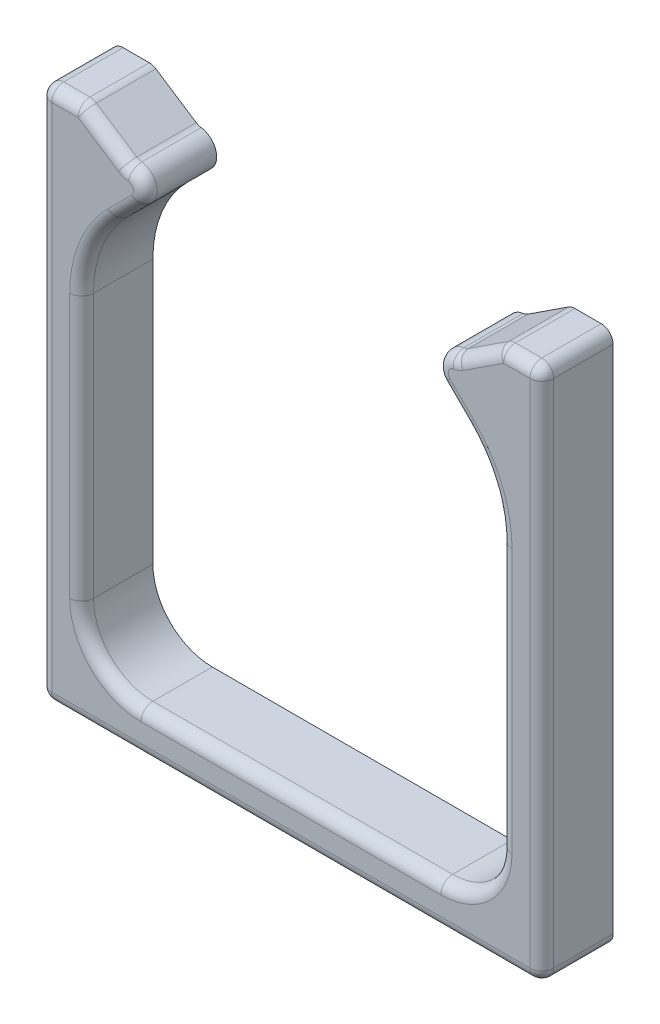
from build123d import *

# Parameters (mm, degrees)
BOSS_EXTRUDE1_DEPTH = 6
FILLET2_R           = 1


with BuildPart() as part:
    # Sketch1 → Boss-Extrude1 (new body)
    with BuildSketch(Plane.XY):
        with BuildLine():
            ThreePointArc((-157.718887647, -39.971100876), (-157.425994428, -40.678207657), (-156.718887647, -40.971100876))
            Line((-156.718887647, -40.971100876), (-154.209280647, -40.971100876))
            Line((-154.209280647, -40.971100876), (-118.966369371, -40.971100876))
            Line((-118.966369371, -40.971100876), (-116.875365395, -40.971100876))
            Line((-116.875365395, -40.971100876), (-116.456762371, -40.971100876))
            ThreePointArc((-116.456762371, -40.971100876), (-115.749655589, -40.678207657), (-115.456762371, -39.971100876))
            Line((-115.456762371, -39.971100876), (-115.456762371, 3.028899124))
            ThreePointArc((-115.456762371, 3.028899124), (-115.749655589, 3.736005905), (-116.456762371, 4.028899124))
            Line((-116.456762371, 4.028899124), (-118.668700725, 4.028899124))
            ThreePointArc((-118.668700725, 4.028899124), (-118.953997988, 3.987338205), (-119.215580818, 3.866110067))
            Line((-119.215580818, 3.866110067), (-122.622400092, 1.640719134))
            ThreePointArc((-122.622400092, 1.640719134), (-122.820936659, 1.540563133), (-123.036698115, 1.486758046))
            ThreePointArc((-123.036698115, 1.486758046), (-124.259059599, 0.479679308), (-123.896981272, -1.062161951))
            Line((-123.896981272, -1.062161951), (-121.905327613, -3.048179664))
            ThreePointArc((-121.905327613, -3.048179664), (-119.730287475, -6.295880771), (-118.966369371, -10.129259334))
            Line((-118.966369371, -10.129259334), (-118.966369371, -32.384364229))
            ThreePointArc((-118.966369371, -32.384364229), (-120.430835465, -35.919898135), (-123.966369371, -37.384364229))
            Line((-123.966369371, -37.384364229), (-149.209280647, -37.384364229))
            ThreePointArc((-149.209280647, -37.384364229), (-152.744814552, -35.919898135), (-154.209280647, -32.384364229))
            Line((-154.209280647, -32.384364229), (-154.209280647, -10.129259334))
            ThreePointArc((-154.209280647, -10.129259334), (-153.445362542, -6.295880771), (-151.270322404, -3.048179664))
            Line((-151.270322404, -3.048179664), (-149.278668745, -1.062161951))
            ThreePointArc((-149.278668745, -1.062161951), (-148.916590418, 0.479679308), (-150.138951903, 1.486758046))
            ThreePointArc((-150.138951903, 1.486758046), (-150.354713358, 1.540563133), (-150.553249925, 1.640719134))
            Line((-150.553249925, 1.640719134), (-153.960069199, 3.866110067))
            ThreePointArc((-153.960069199, 3.866110067), (-154.221652029, 3.987338205), (-154.506949292, 4.028899124))
            Line((-154.506949292, 4.028899124), (-156.718887647, 4.028899124))
            ThreePointArc((-156.718887647, 4.028899124), (-157.425994428, 3.736005905), (-157.718887647, 3.028899124))
            Line((-157.718887647, 3.028899124), (-157.718887647, -39.971100876))
        make_face()
    extrude(amount=BOSS_EXTRUDE1_DEPTH)

    # Fillet2
    fillet2_edges = [part.edges().sort_by_distance(p)[0] for p in [
        (-122.820936659, 1.540563133, 6),
        (-124.259059599, 0.479679308, 6),
        (-154.209280647, -21.256811782, 6),
        (-122.901154442, -2.055170807, 6),
        (-119.730287475, -6.295880771, 6),
        (-118.966369371, -21.256811782, 6),
        (-120.430835465, -35.919898135, 6),
        (-136.587825009, -37.384364229, 6),
        (-153.445362542, -6.295880771, 6),
        (-150.274495575, -2.055170807, 6),
        (-148.916590418, 0.479679308, 6),
        (-150.354713358, 1.540563133, 6),
        (-152.256659562, 2.7534146, 6),
        (-154.221652029, 3.987338205, 6),
        (-155.612918469, 4.028899124, 6),
        (-157.425994428, 3.736005905, 6),
        (-157.718887647, -18.471100876, 6),
        (-152.744814552, -35.919898135, 6),
        (-157.425994428, -40.678207657, 6),
        (-136.587825009, -40.971100876, 6),
        (-115.749655589, -40.678207657, 6),
        (-115.456762371, -18.471100876, 6),
        (-115.749655589, 3.736005905, 6),
        (-117.562731548, 4.028899124, 6),
        (-118.953997988, 3.987338205, 6),
        (-120.918990455, 2.7534146, 6),
    ]]
    fillet(fillet2_edges, radius=FILLET2_R)


solid = part.part
